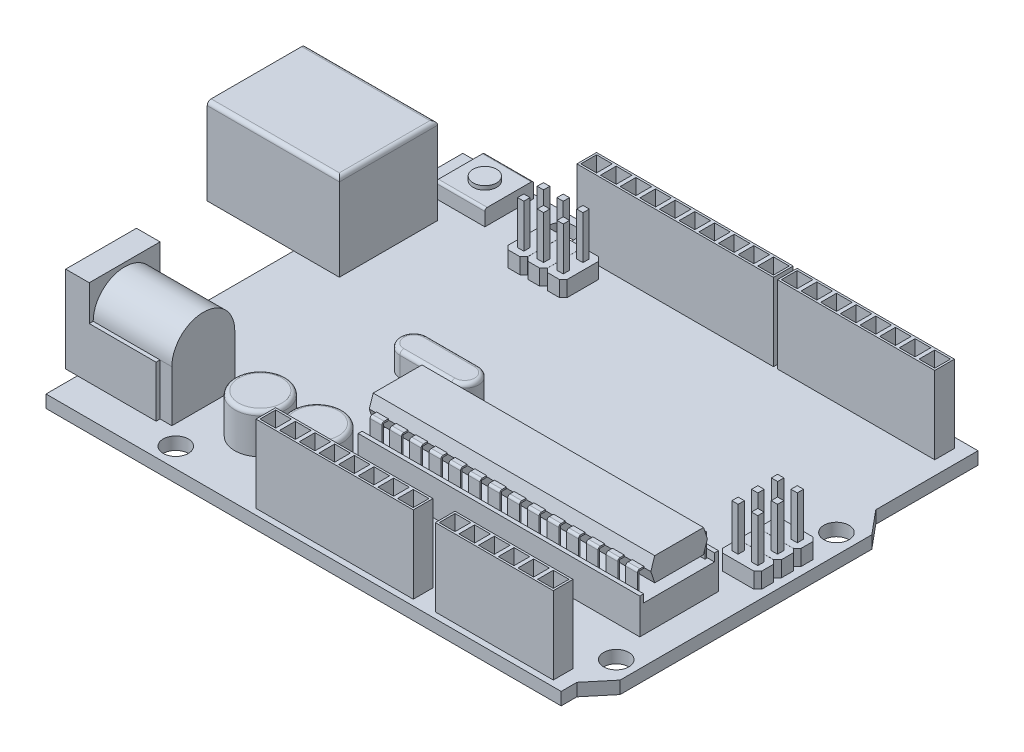
from build123d import *

# Parameters (mm, degrees)
SKETCH_1_R                     = 1.6
EXTRUDE_1_DEPTH                = 1.6
SKETCH_2_W                     = 25
SKETCH_2_H                     = 2.5
SKETCH_2_W_2                   = 2
SKETCH_2_H_2                   = 2
SKETCH_2_W_3                   = 20
SKETCH_2_W_4                   = 15
EXTRUDE_2_DEPTH                = 9.84
SKETCH_4_W                     = 16.8
SKETCH_4_H                     = 12.5
EXTRUDE_3_DEPTH                = 11
SKETCH_5_W                     = 5.3
SKETCH_5_H                     = 3
CUT_EXTRUDE_1_DEPTH            = 10
SKETCH_7_W                     = 9
SKETCH_7_H                     = 11
SKETCH_7_R                     = 3.25
EXTRUDE_4_DEPTH                = 1.5
EXTRUDE_4_DEPTH_BACK           = 10
CUT_EXTRUDE_2_DEPTH            = 8.5
EXTRUDE_5_DEPTH                = 1.5
SKETCH_10_R                    = 3.25
EXTRUDE_6_DEPTH                = 5
FILLET_1_R                     = 0.5
FILLET_2_R                     = 0.5
SKETCH_11_R                    = 1
EXTRUDE_7_DEPTH                = 10
FILLET_3_R                     = 1
EXTRUDE_8_DEPTH                = 3
FILLET_4_R                     = 0.5
SKETCH_13_W                    = 35.8
SKETCH_13_H                    = 10
EXTRUDE_9_DEPTH                = 8
CUT_EXTRUDE_3_DEPTH            = 35.8
SKETCH_15_W                    = 10
SKETCH_15_H                    = 1.5
CUT_EXTRUDE_4_DEPTH            = 35.8
SKETCH_16_W                    = 0.5
SKETCH_16_H                    = 1
EXTRUDE_10_DEPTH               = 35.8
EXTRUDE_11_DEPTH               = 1.5
FILLET_5_R                     = 0.3
PATTERN_LINEAR_2_COUNT         = 14
PATTERN_LINEAR_2_PITCH         = 2.5
FILLET_5_OF_PATTERN_LINEAR_2_R = 0.3
EXTRUDE_12_DEPTH               = 2
SKETCH_19_W                    = 0.8
SKETCH_19_H                    = 0.8
EXTRUDE_13_DEPTH               = 5.5
PATTERN_LINEAR_3_COUNT         = 3
PATTERN_LINEAR_3_PITCH         = 2.51
EXTRUDE_14_DEPTH               = 2
SKETCH_21_W                    = 0.8
SKETCH_21_H                    = 0.8
EXTRUDE_15_DEPTH               = 5.5
PATTERN_LINEAR_4_COUNT         = 3
PATTERN_LINEAR_4_PITCH         = 2.51
SKETCH_22_W                    = 6.2
SKETCH_22_H                    = 6.2
EXTRUDE_16_DEPTH               = 2
SKETCH_23_R                    = 1.5
EXTRUDE_17_DEPTH               = 0.5
FILLET_6_R                     = 0.3


with BuildPart() as part:
    # 스케치1 → 보스-돌출1 (new body)
    with BuildSketch(Plane(origin=(0, 0, 0), x_dir=(1, 0, 0), z_dir=(0, 1, 0))):
        Polygon((0, 0), (0, 53), (65.5, 53), (65.5, 40), (68, 37), (68, 5), (65.5, 2), (65.5, 0), align=None)
        with Locations((15, 50.5)):
            Circle(SKETCH_1_R, mode=Mode.SUBTRACT)
        with Locations((65.5, 35)):
            Circle(SKETCH_1_R, mode=Mode.SUBTRACT)
        with Locations((65.5, 7)):
            Circle(SKETCH_1_R, mode=Mode.SUBTRACT)
        with Locations((14, 2.5)):
            Circle(SKETCH_1_R, mode=Mode.SUBTRACT)
    extrude(amount=EXTRUDE_1_DEPTH)

    # 스케치2 → 보스-돌출2 (add)
    with BuildSketch(Plane(origin=(0, 1.6, 0), x_dir=(1, 0, 0), z_dir=(0, 1, 0))):
        with Locations((30.75, 50.5)):
            Rectangle(SKETCH_2_W, SKETCH_2_H)
        with Locations((42, 50.5)):
            Rectangle(SKETCH_2_W_2, SKETCH_2_H_2, mode=Mode.SUBTRACT)
        with Locations((39.5, 50.5)):
            Rectangle(SKETCH_2_W_2, SKETCH_2_H_2, mode=Mode.SUBTRACT)
        with Locations((37, 50.5)):
            Rectangle(SKETCH_2_W_2, SKETCH_2_H_2, mode=Mode.SUBTRACT)
        with Locations((34.5, 50.5)):
            Rectangle(SKETCH_2_W_2, SKETCH_2_H_2, mode=Mode.SUBTRACT)
        with Locations((32, 50.5)):
            Rectangle(SKETCH_2_W_2, SKETCH_2_H_2, mode=Mode.SUBTRACT)
        with Locations((29.5, 50.5)):
            Rectangle(SKETCH_2_W_2, SKETCH_2_H_2, mode=Mode.SUBTRACT)
        with Locations((27, 50.5)):
            Rectangle(SKETCH_2_W_2, SKETCH_2_H_2, mode=Mode.SUBTRACT)
        with Locations((24.5, 50.5)):
            Rectangle(SKETCH_2_W_2, SKETCH_2_H_2, mode=Mode.SUBTRACT)
        with Locations((22, 50.5)):
            Rectangle(SKETCH_2_W_2, SKETCH_2_H_2, mode=Mode.SUBTRACT)
        with Locations((19.5, 50.5)):
            Rectangle(SKETCH_2_W_2, SKETCH_2_H_2, mode=Mode.SUBTRACT)
        with Locations((53.75, 50.5)):
            Rectangle(SKETCH_2_W_3, SKETCH_2_H)
        with Locations((62.5, 50.5)):
            Rectangle(SKETCH_2_W_2, SKETCH_2_H_2, mode=Mode.SUBTRACT)
        with Locations((60, 50.5)):
            Rectangle(SKETCH_2_W_2, SKETCH_2_H_2, mode=Mode.SUBTRACT)
        with Locations((57.5, 50.5)):
            Rectangle(SKETCH_2_W_2, SKETCH_2_H_2, mode=Mode.SUBTRACT)
        with Locations((55, 50.5)):
            Rectangle(SKETCH_2_W_2, SKETCH_2_H_2, mode=Mode.SUBTRACT)
        with Locations((52.5, 50.5)):
            Rectangle(SKETCH_2_W_2, SKETCH_2_H_2, mode=Mode.SUBTRACT)
        with Locations((50, 50.5)):
            Rectangle(SKETCH_2_W_2, SKETCH_2_H_2, mode=Mode.SUBTRACT)
        with Locations((47.5, 50.5)):
            Rectangle(SKETCH_2_W_2, SKETCH_2_H_2, mode=Mode.SUBTRACT)
        with Locations((45, 50.5)):
            Rectangle(SKETCH_2_W_2, SKETCH_2_H_2, mode=Mode.SUBTRACT)
        with Locations((56.25, 2)):
            Rectangle(SKETCH_2_W_4, SKETCH_2_H)
        with Locations((62.5, 2)):
            Rectangle(SKETCH_2_W_2, SKETCH_2_H_2, mode=Mode.SUBTRACT)
        with Locations((60, 2)):
            Rectangle(SKETCH_2_W_2, SKETCH_2_H_2, mode=Mode.SUBTRACT)
        with Locations((57.5, 2)):
            Rectangle(SKETCH_2_W_2, SKETCH_2_H_2, mode=Mode.SUBTRACT)
        with Locations((55, 2)):
            Rectangle(SKETCH_2_W_2, SKETCH_2_H_2, mode=Mode.SUBTRACT)
        with Locations((52.5, 2)):
            Rectangle(SKETCH_2_W_2, SKETCH_2_H_2, mode=Mode.SUBTRACT)
        with Locations((50, 2)):
            Rectangle(SKETCH_2_W_2, SKETCH_2_H_2, mode=Mode.SUBTRACT)
        with Locations((35.95, 2)):
            Rectangle(SKETCH_2_W_3, SKETCH_2_H)
        with Locations((44.7, 2)):
            Rectangle(SKETCH_2_W_2, SKETCH_2_H_2, mode=Mode.SUBTRACT)
        with Locations((42.2, 2)):
            Rectangle(SKETCH_2_W_2, SKETCH_2_H_2, mode=Mode.SUBTRACT)
        with Locations((39.7, 2)):
            Rectangle(SKETCH_2_W_2, SKETCH_2_H_2, mode=Mode.SUBTRACT)
        with Locations((37.2, 2)):
            Rectangle(SKETCH_2_W_2, SKETCH_2_H_2, mode=Mode.SUBTRACT)
        with Locations((34.7, 2)):
            Rectangle(SKETCH_2_W_2, SKETCH_2_H_2, mode=Mode.SUBTRACT)
        with Locations((32.2, 2)):
            Rectangle(SKETCH_2_W_2, SKETCH_2_H_2, mode=Mode.SUBTRACT)
        with Locations((29.7, 2)):
            Rectangle(SKETCH_2_W_2, SKETCH_2_H_2, mode=Mode.SUBTRACT)
        with Locations((27.2, 2)):
            Rectangle(SKETCH_2_W_2, SKETCH_2_H_2, mode=Mode.SUBTRACT)
    extrude(amount=EXTRUDE_2_DEPTH)

    # 스케치4 → 보스-돌출3 (add)
    with BuildSketch(Plane(origin=(0, 1.6, 0), x_dir=(1, 0, 0), z_dir=(0, 1, 0))):
        with Locations((-2.6, 37.75)):
            Rectangle(SKETCH_4_W, SKETCH_4_H)
    extrude(amount=EXTRUDE_3_DEPTH)

    # 스케치5 → 컷-돌출1 (cut)
    with BuildSketch(Plane.ZY.offset(11)):
        Polygon((-42.5, 9), (-42.5, 3.1), (-33, 3.1), (-33, 9), (-35.1, 11.1), (-40.4, 11.1), align=None)
        with Locations((-37.75, 7.5)):
            Rectangle(SKETCH_5_W, SKETCH_5_H, mode=Mode.SUBTRACT)
    extrude(amount=-CUT_EXTRUDE_1_DEPTH, mode=Mode.SUBTRACT)

    # 스케치7 → 보스-돌출4 (add, two sides)
    with BuildSketch(Plane.ZY) as extrude_4_sk:
        with Locations((-8.5, 7.1)):
            Rectangle(SKETCH_7_W, SKETCH_7_H)
        with Locations((-8.5, 8.1)):
            Circle(SKETCH_7_R, mode=Mode.SUBTRACT)
    extrude(amount=EXTRUDE_4_DEPTH)
    extrude(extrude_4_sk.sketch, amount=-EXTRUDE_4_DEPTH_BACK)

    # 스케치8 → 컷-돌출2 (cut)
    with BuildSketch(Plane(origin=(10, 0, 0), x_dir=(0, 0, -1), z_dir=(1, 0, 0))):
        with BuildLine():
            Line((4.5, 8.1), (4, 8.1))
            Line((4, 8.1), (4, 12.6))
            Line((4, 12.6), (13, 12.6))
            Line((13, 12.6), (13, 8.1))
            Line((13, 8.1), (12.5, 8.1))
            ThreePointArc((12.5, 8.1), (8.5, 12.1), (4.5, 8.1))
        make_face()
    extrude(amount=-CUT_EXTRUDE_2_DEPTH, mode=Mode.SUBTRACT)

    # 스케치9 → 보스-돌출5 (add)
    with BuildSketch(Plane(origin=(10, 0, 0), x_dir=(0, 0, -1), z_dir=(1, 0, 0))):
        with BuildLine():
            Line((4.5, 8.1), (4.5, 1.6))
            Line((4.5, 1.6), (12.5, 1.6))
            Line((12.5, 1.6), (12.5, 8.1))
            ThreePointArc((12.5, 8.1), (8.5, 12.1), (4.5, 8.1))
        make_face()
    extrude(amount=EXTRUDE_5_DEPTH)

    # 스케치10 → 보스-돌출6 (add)
    with BuildSketch(Plane(origin=(0, 1.6, 0), x_dir=(1, 0, 0), z_dir=(0, 1, 0))):
        with Locations((18.25, 9)):
            Circle(SKETCH_10_R)
        with Locations((25.45, 9)):
            Circle(SKETCH_10_R)
    extrude(amount=EXTRUDE_6_DEPTH)

    # 필렛1
    fillet_1_edges = [part.edges().sort_by_distance(p)[0] for p in [
        (15, 6.6, -9),
        (22.2, 6.6, -9),
    ]]
    fillet(fillet_1_edges, radius=FILLET_1_R)

    # 필렛2
    fillet_2_edges = [part.edges().sort_by_distance(p)[0] for p in [
        (-2.6, 12.6, -31.5),
        (5.8, 12.6, -37.75),
        (-2.6, 12.6, -44),
    ]]
    fillet(fillet_2_edges, radius=FILLET_2_R)

    # 스케치11 → 보스-돌출7 (add)
    with BuildSketch(Plane.ZY.offset(-10)):
        with Locations((-8.5, 8.1)):
            Circle(SKETCH_11_R)
    extrude(amount=EXTRUDE_7_DEPTH)

    # 필렛3
    fillet_3_edges = [part.edges().sort_by_distance(p)[0] for p in [
        (0, 8.1, -9.5),
    ]]
    fillet(fillet_3_edges, radius=FILLET_3_R)

    # 스케치12 → 보스-돌출8 (add)
    with BuildSketch(Plane(origin=(0, 1.6, 0), x_dir=(1, 0, 0), z_dir=(0, 1, 0))):
        with BuildLine():
            Line((20.75, 27.75), (27.25, 27.75))
            ThreePointArc((27.25, 27.75), (29, 26), (27.25, 24.25))
            Line((27.25, 24.25), (20.75, 24.25))
            ThreePointArc((20.75, 24.25), (19, 26), (20.75, 27.75))
        make_face()
    extrude(amount=EXTRUDE_8_DEPTH)

    # 필렛4
    fillet_4_edges = [part.edges().sort_by_distance(p)[0] for p in [
        (19, 4.6, -26),
        (24, 4.6, -24.25),
        (29, 4.6, -26),
        (24, 4.6, -27.75),
    ]]
    fillet(fillet_4_edges, radius=FILLET_4_R)

    # 스케치13 → 보스-돌출9 (add)
    with BuildSketch(Plane(origin=(0, 1.6, 0), x_dir=(1, 0, 0), z_dir=(0, 1, 0))):
        with Locations((46.6, 16)):
            Rectangle(SKETCH_13_W, SKETCH_13_H)
    extrude(amount=EXTRUDE_9_DEPTH)

    # 스케치14 → 컷-돌출3 (cut)
    with BuildSketch(Plane(origin=(64.5, 0, 0), x_dir=(0, 0, -1), z_dir=(1, 0, 0))):
        Polygon((12.9, 9.6), (12.4, 8.1), (12.9, 6.6), (11, 6.6), (11, 9.6), align=None)
        Polygon((19.1, 9.6), (19.6, 8.1), (19.1, 6.6), (21, 6.6), (21, 9.6), align=None)
    extrude(amount=-CUT_EXTRUDE_3_DEPTH, mode=Mode.SUBTRACT)

    # 스케치15 → 컷-돌출4 (cut)
    with BuildSketch(Plane(origin=(64.5, 0, 0), x_dir=(0, 0, -1), z_dir=(1, 0, 0))):
        with Locations((16, 5.85)):
            Rectangle(SKETCH_15_W, SKETCH_15_H)
    extrude(amount=-CUT_EXTRUDE_4_DEPTH, mode=Mode.SUBTRACT)

    # 스케치16 → 보스-돌출10 (add)
    with BuildSketch(Plane(origin=(64.5, 0, 0), x_dir=(0, 0, -1), z_dir=(1, 0, 0))):
        with Locations((11.25, 5.6)):
            Rectangle(SKETCH_16_W, SKETCH_16_H)
        with Locations((20.75, 5.6)):
            Rectangle(SKETCH_16_W, SKETCH_16_H)
    extrude(amount=-EXTRUDE_10_DEPTH)

    # 스케치17 → 보스-돌출11 (add)
    with BuildSketch(Plane(origin=(63.6, 0, 0), x_dir=(0, 0, -1), z_dir=(1, 0, 0))):
        Polygon((12.433333333, 8.2), (12.433333333, 8), (11.8, 8), (11.8, 5.1), (11.6, 5.1), (11.6, 8.2), align=None)
        Polygon((20.4, 5.1), (20.4, 8.2), (19.566666667, 8.2), (19.566666667, 8), (20.2, 8), (20.2, 5.1), align=None)
    extrude_11 = extrude(amount=-EXTRUDE_11_DEPTH)

    # 필렛5
    fillet_5_edges = [part.edges().sort_by_distance(p)[0] for p in [
        (62.85, 8.2, -20.4),
        (62.85, 8.2, -11.6),
    ]]
    fillet(fillet_5_edges, radius=FILLET_5_R)

    # 선형 패턴2: 보스-돌출11 ×14
    with Locations(*[(-i * PATTERN_LINEAR_2_PITCH, 0, 0) for i in range(1, PATTERN_LINEAR_2_COUNT)]):
        add(extrude_11)

    # 필렛5 of 선형 패턴2
    fillet_5_of_pattern_linear_2_edges = [part.edges().sort_by_distance(p)[0] for p in [
        (60.35, 8.2, -20.4),
        (60.35, 8.2, -11.6),
        (57.85, 8.2, -20.4),
        (57.85, 8.2, -11.6),
        (55.35, 8.2, -20.4),
        (55.35, 8.2, -11.6),
        (52.85, 8.2, -20.4),
        (52.85, 8.2, -11.6),
        (50.35, 8.2, -20.4),
        (50.35, 8.2, -11.6),
        (47.85, 8.2, -20.4),
        (47.85, 8.2, -11.6),
        (45.35, 8.2, -20.4),
        (45.35, 8.2, -11.6),
        (42.85, 8.2, -20.4),
        (42.85, 8.2, -11.6),
        (40.35, 8.2, -20.4),
        (40.35, 8.2, -11.6),
        (37.85, 8.2, -20.4),
        (37.85, 8.2, -11.6),
        (35.35, 8.2, -20.4),
        (35.35, 8.2, -11.6),
        (32.85, 8.2, -20.4),
        (32.85, 8.2, -11.6),
        (30.35, 8.2, -20.4),
        (30.35, 8.2, -11.6),
    ]]
    fillet(fillet_5_of_pattern_linear_2_edges, radius=FILLET_5_OF_PATTERN_LINEAR_2_R)

    # 스케치18 → 보스-돌출12 (add)
    with BuildSketch(Plane(origin=(0, 1.6, 0), x_dir=(1, 0, 0), z_dir=(0, 1, 0))):
        Polygon((66.5, 26), (62.5, 26), (62, 25.5), (62, 24), (62.5, 23.5), (66.5, 23.5), (67, 24), (67, 25.5), align=None)
    extrude_12 = extrude(amount=EXTRUDE_12_DEPTH)

    # 스케치19 → 보스-돌출13 (add)
    with BuildSketch(Plane(origin=(0, 3.6, 0), x_dir=(1, 0, 0), z_dir=(0, 1, 0))):
        with Locations((63.25, 24.75)):
            Rectangle(SKETCH_19_W, SKETCH_19_H)
        with Locations((65.75, 24.75)):
            Rectangle(SKETCH_19_W, SKETCH_19_H)
    extrude_13 = extrude(amount=EXTRUDE_13_DEPTH)

    # 선형 패턴3: 보스-돌출12, 보스-돌출13 ×3
    with Locations(*[(0, 0, -i * PATTERN_LINEAR_3_PITCH) for i in range(1, PATTERN_LINEAR_3_COUNT)]):
        add(extrude_12)
        add(extrude_13)

    # 스케치20 → 보스-돌출14 (add)
    with BuildSketch(Plane(origin=(0, 1.6, 0), x_dir=(1, 0, 0), z_dir=(0, 1, 0))):
        Polygon((15, 47.75), (15, 43.75), (15.5, 43.25), (17, 43.25), (17.5, 43.75), (17.5, 47.75), (17, 48.25), (15.5, 48.25), align=None)
    extrude_14 = extrude(amount=EXTRUDE_14_DEPTH)

    # 스케치21 → 보스-돌출15 (add)
    with BuildSketch(Plane(origin=(0, 3.6, 0), x_dir=(1, 0, 0), z_dir=(0, 1, 0))):
        with Locations((16.25, 47)):
            Rectangle(SKETCH_21_W, SKETCH_21_H)
        with Locations((16.25, 44.5)):
            Rectangle(SKETCH_21_W, SKETCH_21_H)
    extrude_15 = extrude(amount=EXTRUDE_15_DEPTH)

    # 선형 패턴4: 보스-돌출14, 보스-돌출15 ×3
    with Locations(*[(i * PATTERN_LINEAR_4_PITCH, 0, 0) for i in range(1, PATTERN_LINEAR_4_COUNT)]):
        add(extrude_14)
        add(extrude_15)

    # 스케치22 → 보스-돌출16 (add)
    with BuildSketch(Plane(origin=(0, 1.6, 0), x_dir=(1, 0, 0), z_dir=(0, 1, 0))):
        with Locations((6.4, 49.4)):
            Rectangle(SKETCH_22_W, SKETCH_22_H)
    extrude(amount=EXTRUDE_16_DEPTH)

    # 스케치23 → 보스-돌출17 (add)
    with BuildSketch(Plane(origin=(0, 3.6, 0), x_dir=(1, 0, 0), z_dir=(0, 1, 0))):
        with Locations((6.4, 49.4)):
            Circle(SKETCH_23_R)
    extrude(amount=EXTRUDE_17_DEPTH)

    # 필렛6
    fillet_6_edges = [part.edges().sort_by_distance(p)[0] for p in [
        (6.4, 3.6, -46.3),
        (6.4, 3.6, -52.5),
    ]]
    fillet(fillet_6_edges, radius=FILLET_6_R)


solid = part.part
